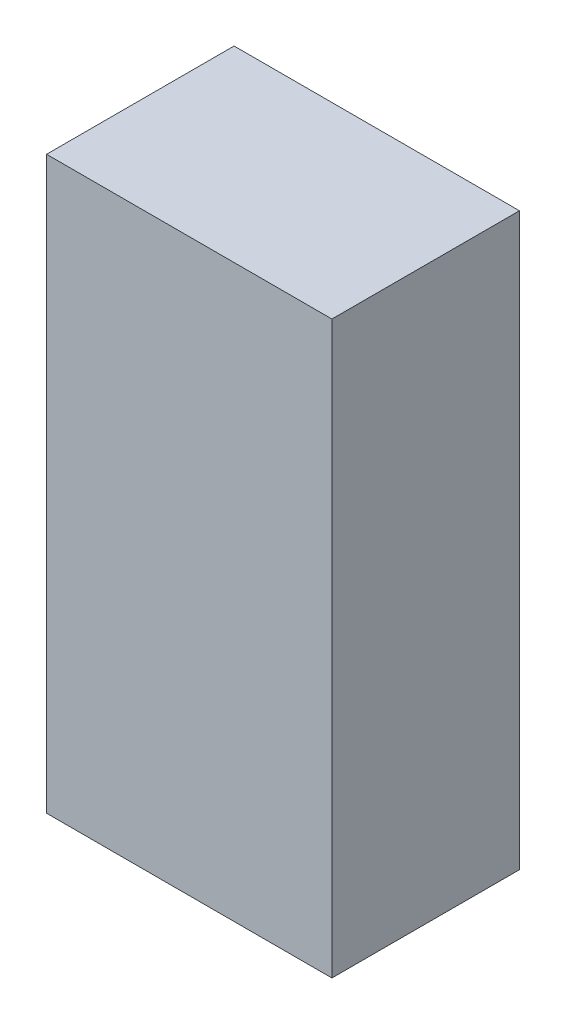
from build123d import *

# Parameters (mm, degrees)
SKETCH1_W           = 35
SKETCH1_H           = 23
BOSS_EXTRUDE1_DEPTH = 70


with BuildPart() as part:
    # Sketch1 → Boss-Extrude1 (new body)
    with BuildSketch(Plane(origin=(0, 0, 0), x_dir=(1, 0, 0), z_dir=(0, 1, 0))):
        Rectangle(SKETCH1_W, SKETCH1_H)
    extrude(amount=BOSS_EXTRUDE1_DEPTH)


solid = part.part
